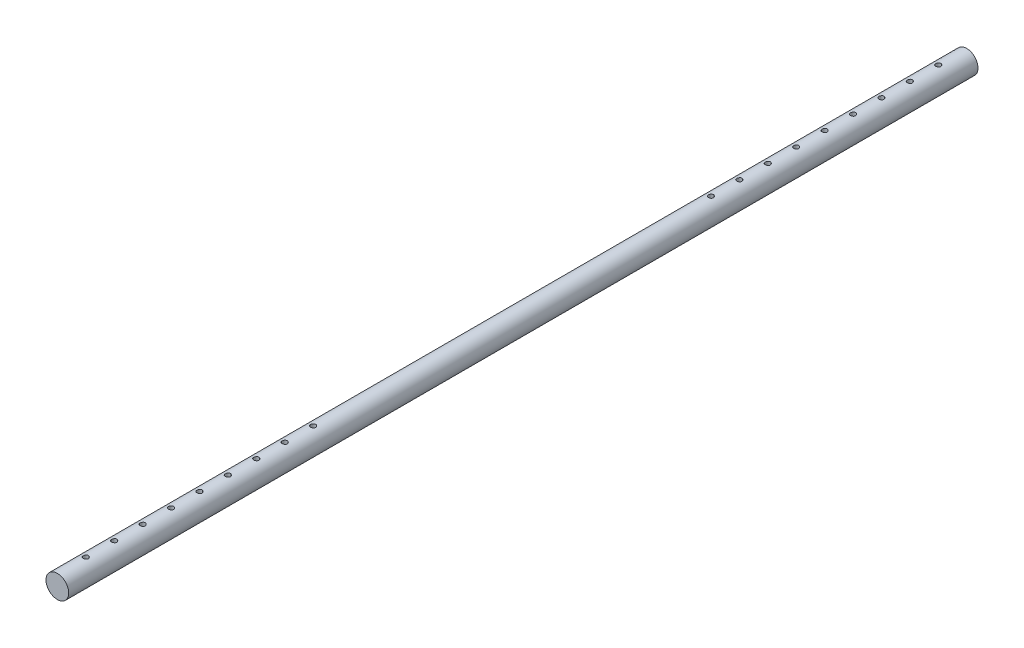
from build123d import *

# Parameters (mm, degrees)
SKETCH1_R                      = 10
BOSS_EXTRUDE1_DEPTH            = 800
CUT_EXTRUDE1_REACH             = 12
SKETCH2_R                      = 2.25
CUT_EXTRUDE1_DIRECTION_2_REACH = 12


with BuildPart() as part:
    # Sketch1 → Boss-Extrude1 (new body)
    with BuildSketch(Plane.XY):
        Circle(SKETCH1_R)
    extrude(amount=BOSS_EXTRUDE1_DEPTH)

    # Sketch2 → Cut-Extrude1 (cut, up to next)
    with BuildSketch(Plane(origin=(0, 0, 0), x_dir=(1, 0, 0), z_dir=(0, 1, 0)), mode=Mode.PRIVATE) as cut_extrude1_sk1:
        with Locations((0, -25)):
            Circle(SKETCH2_R)
    cut_extrude1_tool1 = extrude(cut_extrude1_sk1.sketch, amount=-CUT_EXTRUDE1_REACH, mode=Mode.PRIVATE) & part.part
    add(cut_extrude1_tool1.solids().sort_by_distance((0, 0, 25))[0], mode=Mode.SUBTRACT)
    # Sketch2 → Cut-Extrude1 (cut, up to next)
    with BuildSketch(Plane(origin=(0, 0, 0), x_dir=(1, 0, 0), z_dir=(0, 1, 0)), mode=Mode.PRIVATE) as cut_extrude1_sk2:
        with Locations((0, -775)):
            Circle(SKETCH2_R)
    cut_extrude1_tool2 = extrude(cut_extrude1_sk2.sketch, amount=-CUT_EXTRUDE1_REACH, mode=Mode.PRIVATE) & part.part
    add(cut_extrude1_tool2.solids().sort_by_distance((0, 0, 775))[0], mode=Mode.SUBTRACT)
    # Sketch2 → Cut-Extrude1 (cut, up to next)
    with BuildSketch(Plane(origin=(0, 0, 0), x_dir=(1, 0, 0), z_dir=(0, 1, 0)), mode=Mode.PRIVATE) as cut_extrude1_sk3:
        with Locations((0, -750)):
            Circle(SKETCH2_R)
    cut_extrude1_tool3 = extrude(cut_extrude1_sk3.sketch, amount=-CUT_EXTRUDE1_REACH, mode=Mode.PRIVATE) & part.part
    add(cut_extrude1_tool3.solids().sort_by_distance((0, 0, 750))[0], mode=Mode.SUBTRACT)
    # Sketch2 → Cut-Extrude1 (cut, up to next)
    with BuildSketch(Plane(origin=(0, 0, 0), x_dir=(1, 0, 0), z_dir=(0, 1, 0)), mode=Mode.PRIVATE) as cut_extrude1_sk4:
        with Locations((0, -725)):
            Circle(SKETCH2_R)
    cut_extrude1_tool4 = extrude(cut_extrude1_sk4.sketch, amount=-CUT_EXTRUDE1_REACH, mode=Mode.PRIVATE) & part.part
    add(cut_extrude1_tool4.solids().sort_by_distance((0, 0, 725))[0], mode=Mode.SUBTRACT)
    # Sketch2 → Cut-Extrude1 (cut, up to next)
    with BuildSketch(Plane(origin=(0, 0, 0), x_dir=(1, 0, 0), z_dir=(0, 1, 0)), mode=Mode.PRIVATE) as cut_extrude1_sk5:
        with Locations((0, -50)):
            Circle(SKETCH2_R)
    cut_extrude1_tool5 = extrude(cut_extrude1_sk5.sketch, amount=-CUT_EXTRUDE1_REACH, mode=Mode.PRIVATE) & part.part
    add(cut_extrude1_tool5.solids().sort_by_distance((0, 0, 50))[0], mode=Mode.SUBTRACT)
    # Sketch2 → Cut-Extrude1 (cut, up to next)
    with BuildSketch(Plane(origin=(0, 0, 0), x_dir=(1, 0, 0), z_dir=(0, 1, 0)), mode=Mode.PRIVATE) as cut_extrude1_sk6:
        with Locations((0, -75)):
            Circle(SKETCH2_R)
    cut_extrude1_tool6 = extrude(cut_extrude1_sk6.sketch, amount=-CUT_EXTRUDE1_REACH, mode=Mode.PRIVATE) & part.part
    add(cut_extrude1_tool6.solids().sort_by_distance((0, 0, 75))[0], mode=Mode.SUBTRACT)
    # Sketch2 → Cut-Extrude1 (cut, up to next)
    with BuildSketch(Plane(origin=(0, 0, 0), x_dir=(1, 0, 0), z_dir=(0, 1, 0)), mode=Mode.PRIVATE) as cut_extrude1_sk7:
        with Locations((0, -100)):
            Circle(SKETCH2_R)
    cut_extrude1_tool7 = extrude(cut_extrude1_sk7.sketch, amount=-CUT_EXTRUDE1_REACH, mode=Mode.PRIVATE) & part.part
    add(cut_extrude1_tool7.solids().sort_by_distance((0, 0, 100))[0], mode=Mode.SUBTRACT)
    # Sketch2 → Cut-Extrude1 (cut, up to next)
    with BuildSketch(Plane(origin=(0, 0, 0), x_dir=(1, 0, 0), z_dir=(0, 1, 0)), mode=Mode.PRIVATE) as cut_extrude1_sk8:
        with Locations((0, -125)):
            Circle(SKETCH2_R)
    cut_extrude1_tool8 = extrude(cut_extrude1_sk8.sketch, amount=-CUT_EXTRUDE1_REACH, mode=Mode.PRIVATE) & part.part
    add(cut_extrude1_tool8.solids().sort_by_distance((0, 0, 125))[0], mode=Mode.SUBTRACT)
    # Sketch2 → Cut-Extrude1 (cut, up to next)
    with BuildSketch(Plane(origin=(0, 0, 0), x_dir=(1, 0, 0), z_dir=(0, 1, 0)), mode=Mode.PRIVATE) as cut_extrude1_sk9:
        with Locations((0, -150)):
            Circle(SKETCH2_R)
    cut_extrude1_tool9 = extrude(cut_extrude1_sk9.sketch, amount=-CUT_EXTRUDE1_REACH, mode=Mode.PRIVATE) & part.part
    add(cut_extrude1_tool9.solids().sort_by_distance((0, 0, 150))[0], mode=Mode.SUBTRACT)
    # Sketch2 → Cut-Extrude1 (cut, up to next)
    with BuildSketch(Plane(origin=(0, 0, 0), x_dir=(1, 0, 0), z_dir=(0, 1, 0)), mode=Mode.PRIVATE) as cut_extrude1_sk10:
        with Locations((0, -175)):
            Circle(SKETCH2_R)
    cut_extrude1_tool10 = extrude(cut_extrude1_sk10.sketch, amount=-CUT_EXTRUDE1_REACH, mode=Mode.PRIVATE) & part.part
    add(cut_extrude1_tool10.solids().sort_by_distance((0, 0, 175))[0], mode=Mode.SUBTRACT)
    # Sketch2 → Cut-Extrude1 (cut, up to next)
    with BuildSketch(Plane(origin=(0, 0, 0), x_dir=(1, 0, 0), z_dir=(0, 1, 0)), mode=Mode.PRIVATE) as cut_extrude1_sk11:
        with Locations((0, -200)):
            Circle(SKETCH2_R)
    cut_extrude1_tool11 = extrude(cut_extrude1_sk11.sketch, amount=-CUT_EXTRUDE1_REACH, mode=Mode.PRIVATE) & part.part
    add(cut_extrude1_tool11.solids().sort_by_distance((0, 0, 200))[0], mode=Mode.SUBTRACT)
    # Sketch2 → Cut-Extrude1 (cut, up to next)
    with BuildSketch(Plane(origin=(0, 0, 0), x_dir=(1, 0, 0), z_dir=(0, 1, 0)), mode=Mode.PRIVATE) as cut_extrude1_sk12:
        with Locations((0, -225)):
            Circle(SKETCH2_R)
    cut_extrude1_tool12 = extrude(cut_extrude1_sk12.sketch, amount=-CUT_EXTRUDE1_REACH, mode=Mode.PRIVATE) & part.part
    add(cut_extrude1_tool12.solids().sort_by_distance((0, 0, 225))[0], mode=Mode.SUBTRACT)
    # Sketch2 → Cut-Extrude1 (cut, up to next)
    with BuildSketch(Plane(origin=(0, 0, 0), x_dir=(1, 0, 0), z_dir=(0, 1, 0)), mode=Mode.PRIVATE) as cut_extrude1_sk13:
        with Locations((0, -700)):
            Circle(SKETCH2_R)
    cut_extrude1_tool13 = extrude(cut_extrude1_sk13.sketch, amount=-CUT_EXTRUDE1_REACH, mode=Mode.PRIVATE) & part.part
    add(cut_extrude1_tool13.solids().sort_by_distance((0, 0, 700))[0], mode=Mode.SUBTRACT)
    # Sketch2 → Cut-Extrude1 (cut, up to next)
    with BuildSketch(Plane(origin=(0, 0, 0), x_dir=(1, 0, 0), z_dir=(0, 1, 0)), mode=Mode.PRIVATE) as cut_extrude1_sk14:
        with Locations((0, -675)):
            Circle(SKETCH2_R)
    cut_extrude1_tool14 = extrude(cut_extrude1_sk14.sketch, amount=-CUT_EXTRUDE1_REACH, mode=Mode.PRIVATE) & part.part
    add(cut_extrude1_tool14.solids().sort_by_distance((0, 0, 675))[0], mode=Mode.SUBTRACT)
    # Sketch2 → Cut-Extrude1 (cut, up to next)
    with BuildSketch(Plane(origin=(0, 0, 0), x_dir=(1, 0, 0), z_dir=(0, 1, 0)), mode=Mode.PRIVATE) as cut_extrude1_sk15:
        with Locations((0, -650)):
            Circle(SKETCH2_R)
    cut_extrude1_tool15 = extrude(cut_extrude1_sk15.sketch, amount=-CUT_EXTRUDE1_REACH, mode=Mode.PRIVATE) & part.part
    add(cut_extrude1_tool15.solids().sort_by_distance((0, 0, 650))[0], mode=Mode.SUBTRACT)
    # Sketch2 → Cut-Extrude1 (cut, up to next)
    with BuildSketch(Plane(origin=(0, 0, 0), x_dir=(1, 0, 0), z_dir=(0, 1, 0)), mode=Mode.PRIVATE) as cut_extrude1_sk16:
        with Locations((0, -625)):
            Circle(SKETCH2_R)
    cut_extrude1_tool16 = extrude(cut_extrude1_sk16.sketch, amount=-CUT_EXTRUDE1_REACH, mode=Mode.PRIVATE) & part.part
    add(cut_extrude1_tool16.solids().sort_by_distance((0, 0, 625))[0], mode=Mode.SUBTRACT)
    # Sketch2 → Cut-Extrude1 (cut, up to next)
    with BuildSketch(Plane(origin=(0, 0, 0), x_dir=(1, 0, 0), z_dir=(0, 1, 0)), mode=Mode.PRIVATE) as cut_extrude1_sk17:
        with Locations((0, -600)):
            Circle(SKETCH2_R)
    cut_extrude1_tool17 = extrude(cut_extrude1_sk17.sketch, amount=-CUT_EXTRUDE1_REACH, mode=Mode.PRIVATE) & part.part
    add(cut_extrude1_tool17.solids().sort_by_distance((0, 0, 600))[0], mode=Mode.SUBTRACT)
    # Sketch2 → Cut-Extrude1 (cut, up to next)
    with BuildSketch(Plane(origin=(0, 0, 0), x_dir=(1, 0, 0), z_dir=(0, 1, 0)), mode=Mode.PRIVATE) as cut_extrude1_sk18:
        with Locations((0, -575)):
            Circle(SKETCH2_R)
    cut_extrude1_tool18 = extrude(cut_extrude1_sk18.sketch, amount=-CUT_EXTRUDE1_REACH, mode=Mode.PRIVATE) & part.part
    add(cut_extrude1_tool18.solids().sort_by_distance((0, 0, 575))[0], mode=Mode.SUBTRACT)

    # Sketch2 → Cut-Extrude1 direction 2 (cut, up to next)
    with BuildSketch(Plane(origin=(0, 0, 0), x_dir=(1, 0, 0), z_dir=(0, 1, 0)), mode=Mode.PRIVATE) as cut_extrude1_direction_2_sk1:
        with Locations((0, -25)):
            Circle(SKETCH2_R)
    cut_extrude1_direction_2_tool1 = extrude(cut_extrude1_direction_2_sk1.sketch, amount=CUT_EXTRUDE1_DIRECTION_2_REACH, mode=Mode.PRIVATE) & part.part
    add(cut_extrude1_direction_2_tool1.solids().sort_by_distance((0, 0, 25))[0], mode=Mode.SUBTRACT)
    # Sketch2 → Cut-Extrude1 direction 2 (cut, up to next)
    with BuildSketch(Plane(origin=(0, 0, 0), x_dir=(1, 0, 0), z_dir=(0, 1, 0)), mode=Mode.PRIVATE) as cut_extrude1_direction_2_sk2:
        with Locations((0, -775)):
            Circle(SKETCH2_R)
    cut_extrude1_direction_2_tool2 = extrude(cut_extrude1_direction_2_sk2.sketch, amount=CUT_EXTRUDE1_DIRECTION_2_REACH, mode=Mode.PRIVATE) & part.part
    add(cut_extrude1_direction_2_tool2.solids().sort_by_distance((0, 0, 775))[0], mode=Mode.SUBTRACT)
    # Sketch2 → Cut-Extrude1 direction 2 (cut, up to next)
    with BuildSketch(Plane(origin=(0, 0, 0), x_dir=(1, 0, 0), z_dir=(0, 1, 0)), mode=Mode.PRIVATE) as cut_extrude1_direction_2_sk3:
        with Locations((0, -750)):
            Circle(SKETCH2_R)
    cut_extrude1_direction_2_tool3 = extrude(cut_extrude1_direction_2_sk3.sketch, amount=CUT_EXTRUDE1_DIRECTION_2_REACH, mode=Mode.PRIVATE) & part.part
    add(cut_extrude1_direction_2_tool3.solids().sort_by_distance((0, 0, 750))[0], mode=Mode.SUBTRACT)
    # Sketch2 → Cut-Extrude1 direction 2 (cut, up to next)
    with BuildSketch(Plane(origin=(0, 0, 0), x_dir=(1, 0, 0), z_dir=(0, 1, 0)), mode=Mode.PRIVATE) as cut_extrude1_direction_2_sk4:
        with Locations((0, -725)):
            Circle(SKETCH2_R)
    cut_extrude1_direction_2_tool4 = extrude(cut_extrude1_direction_2_sk4.sketch, amount=CUT_EXTRUDE1_DIRECTION_2_REACH, mode=Mode.PRIVATE) & part.part
    add(cut_extrude1_direction_2_tool4.solids().sort_by_distance((0, 0, 725))[0], mode=Mode.SUBTRACT)
    # Sketch2 → Cut-Extrude1 direction 2 (cut, up to next)
    with BuildSketch(Plane(origin=(0, 0, 0), x_dir=(1, 0, 0), z_dir=(0, 1, 0)), mode=Mode.PRIVATE) as cut_extrude1_direction_2_sk5:
        with Locations((0, -50)):
            Circle(SKETCH2_R)
    cut_extrude1_direction_2_tool5 = extrude(cut_extrude1_direction_2_sk5.sketch, amount=CUT_EXTRUDE1_DIRECTION_2_REACH, mode=Mode.PRIVATE) & part.part
    add(cut_extrude1_direction_2_tool5.solids().sort_by_distance((0, 0, 50))[0], mode=Mode.SUBTRACT)
    # Sketch2 → Cut-Extrude1 direction 2 (cut, up to next)
    with BuildSketch(Plane(origin=(0, 0, 0), x_dir=(1, 0, 0), z_dir=(0, 1, 0)), mode=Mode.PRIVATE) as cut_extrude1_direction_2_sk6:
        with Locations((0, -75)):
            Circle(SKETCH2_R)
    cut_extrude1_direction_2_tool6 = extrude(cut_extrude1_direction_2_sk6.sketch, amount=CUT_EXTRUDE1_DIRECTION_2_REACH, mode=Mode.PRIVATE) & part.part
    add(cut_extrude1_direction_2_tool6.solids().sort_by_distance((0, 0, 75))[0], mode=Mode.SUBTRACT)
    # Sketch2 → Cut-Extrude1 direction 2 (cut, up to next)
    with BuildSketch(Plane(origin=(0, 0, 0), x_dir=(1, 0, 0), z_dir=(0, 1, 0)), mode=Mode.PRIVATE) as cut_extrude1_direction_2_sk7:
        with Locations((0, -100)):
            Circle(SKETCH2_R)
    cut_extrude1_direction_2_tool7 = extrude(cut_extrude1_direction_2_sk7.sketch, amount=CUT_EXTRUDE1_DIRECTION_2_REACH, mode=Mode.PRIVATE) & part.part
    add(cut_extrude1_direction_2_tool7.solids().sort_by_distance((0, 0, 100))[0], mode=Mode.SUBTRACT)
    # Sketch2 → Cut-Extrude1 direction 2 (cut, up to next)
    with BuildSketch(Plane(origin=(0, 0, 0), x_dir=(1, 0, 0), z_dir=(0, 1, 0)), mode=Mode.PRIVATE) as cut_extrude1_direction_2_sk8:
        with Locations((0, -125)):
            Circle(SKETCH2_R)
    cut_extrude1_direction_2_tool8 = extrude(cut_extrude1_direction_2_sk8.sketch, amount=CUT_EXTRUDE1_DIRECTION_2_REACH, mode=Mode.PRIVATE) & part.part
    add(cut_extrude1_direction_2_tool8.solids().sort_by_distance((0, 0, 125))[0], mode=Mode.SUBTRACT)
    # Sketch2 → Cut-Extrude1 direction 2 (cut, up to next)
    with BuildSketch(Plane(origin=(0, 0, 0), x_dir=(1, 0, 0), z_dir=(0, 1, 0)), mode=Mode.PRIVATE) as cut_extrude1_direction_2_sk9:
        with Locations((0, -150)):
            Circle(SKETCH2_R)
    cut_extrude1_direction_2_tool9 = extrude(cut_extrude1_direction_2_sk9.sketch, amount=CUT_EXTRUDE1_DIRECTION_2_REACH, mode=Mode.PRIVATE) & part.part
    add(cut_extrude1_direction_2_tool9.solids().sort_by_distance((0, 0, 150))[0], mode=Mode.SUBTRACT)
    # Sketch2 → Cut-Extrude1 direction 2 (cut, up to next)
    with BuildSketch(Plane(origin=(0, 0, 0), x_dir=(1, 0, 0), z_dir=(0, 1, 0)), mode=Mode.PRIVATE) as cut_extrude1_direction_2_sk10:
        with Locations((0, -175)):
            Circle(SKETCH2_R)
    cut_extrude1_direction_2_tool10 = extrude(cut_extrude1_direction_2_sk10.sketch, amount=CUT_EXTRUDE1_DIRECTION_2_REACH, mode=Mode.PRIVATE) & part.part
    add(cut_extrude1_direction_2_tool10.solids().sort_by_distance((0, 0, 175))[0], mode=Mode.SUBTRACT)
    # Sketch2 → Cut-Extrude1 direction 2 (cut, up to next)
    with BuildSketch(Plane(origin=(0, 0, 0), x_dir=(1, 0, 0), z_dir=(0, 1, 0)), mode=Mode.PRIVATE) as cut_extrude1_direction_2_sk11:
        with Locations((0, -200)):
            Circle(SKETCH2_R)
    cut_extrude1_direction_2_tool11 = extrude(cut_extrude1_direction_2_sk11.sketch, amount=CUT_EXTRUDE1_DIRECTION_2_REACH, mode=Mode.PRIVATE) & part.part
    add(cut_extrude1_direction_2_tool11.solids().sort_by_distance((0, 0, 200))[0], mode=Mode.SUBTRACT)
    # Sketch2 → Cut-Extrude1 direction 2 (cut, up to next)
    with BuildSketch(Plane(origin=(0, 0, 0), x_dir=(1, 0, 0), z_dir=(0, 1, 0)), mode=Mode.PRIVATE) as cut_extrude1_direction_2_sk12:
        with Locations((0, -225)):
            Circle(SKETCH2_R)
    cut_extrude1_direction_2_tool12 = extrude(cut_extrude1_direction_2_sk12.sketch, amount=CUT_EXTRUDE1_DIRECTION_2_REACH, mode=Mode.PRIVATE) & part.part
    add(cut_extrude1_direction_2_tool12.solids().sort_by_distance((0, 0, 225))[0], mode=Mode.SUBTRACT)
    # Sketch2 → Cut-Extrude1 direction 2 (cut, up to next)
    with BuildSketch(Plane(origin=(0, 0, 0), x_dir=(1, 0, 0), z_dir=(0, 1, 0)), mode=Mode.PRIVATE) as cut_extrude1_direction_2_sk13:
        with Locations((0, -700)):
            Circle(SKETCH2_R)
    cut_extrude1_direction_2_tool13 = extrude(cut_extrude1_direction_2_sk13.sketch, amount=CUT_EXTRUDE1_DIRECTION_2_REACH, mode=Mode.PRIVATE) & part.part
    add(cut_extrude1_direction_2_tool13.solids().sort_by_distance((0, 0, 700))[0], mode=Mode.SUBTRACT)
    # Sketch2 → Cut-Extrude1 direction 2 (cut, up to next)
    with BuildSketch(Plane(origin=(0, 0, 0), x_dir=(1, 0, 0), z_dir=(0, 1, 0)), mode=Mode.PRIVATE) as cut_extrude1_direction_2_sk14:
        with Locations((0, -675)):
            Circle(SKETCH2_R)
    cut_extrude1_direction_2_tool14 = extrude(cut_extrude1_direction_2_sk14.sketch, amount=CUT_EXTRUDE1_DIRECTION_2_REACH, mode=Mode.PRIVATE) & part.part
    add(cut_extrude1_direction_2_tool14.solids().sort_by_distance((0, 0, 675))[0], mode=Mode.SUBTRACT)
    # Sketch2 → Cut-Extrude1 direction 2 (cut, up to next)
    with BuildSketch(Plane(origin=(0, 0, 0), x_dir=(1, 0, 0), z_dir=(0, 1, 0)), mode=Mode.PRIVATE) as cut_extrude1_direction_2_sk15:
        with Locations((0, -650)):
            Circle(SKETCH2_R)
    cut_extrude1_direction_2_tool15 = extrude(cut_extrude1_direction_2_sk15.sketch, amount=CUT_EXTRUDE1_DIRECTION_2_REACH, mode=Mode.PRIVATE) & part.part
    add(cut_extrude1_direction_2_tool15.solids().sort_by_distance((0, 0, 650))[0], mode=Mode.SUBTRACT)
    # Sketch2 → Cut-Extrude1 direction 2 (cut, up to next)
    with BuildSketch(Plane(origin=(0, 0, 0), x_dir=(1, 0, 0), z_dir=(0, 1, 0)), mode=Mode.PRIVATE) as cut_extrude1_direction_2_sk16:
        with Locations((0, -625)):
            Circle(SKETCH2_R)
    cut_extrude1_direction_2_tool16 = extrude(cut_extrude1_direction_2_sk16.sketch, amount=CUT_EXTRUDE1_DIRECTION_2_REACH, mode=Mode.PRIVATE) & part.part
    add(cut_extrude1_direction_2_tool16.solids().sort_by_distance((0, 0, 625))[0], mode=Mode.SUBTRACT)
    # Sketch2 → Cut-Extrude1 direction 2 (cut, up to next)
    with BuildSketch(Plane(origin=(0, 0, 0), x_dir=(1, 0, 0), z_dir=(0, 1, 0)), mode=Mode.PRIVATE) as cut_extrude1_direction_2_sk17:
        with Locations((0, -600)):
            Circle(SKETCH2_R)
    cut_extrude1_direction_2_tool17 = extrude(cut_extrude1_direction_2_sk17.sketch, amount=CUT_EXTRUDE1_DIRECTION_2_REACH, mode=Mode.PRIVATE) & part.part
    add(cut_extrude1_direction_2_tool17.solids().sort_by_distance((0, 0, 600))[0], mode=Mode.SUBTRACT)
    # Sketch2 → Cut-Extrude1 direction 2 (cut, up to next)
    with BuildSketch(Plane(origin=(0, 0, 0), x_dir=(1, 0, 0), z_dir=(0, 1, 0)), mode=Mode.PRIVATE) as cut_extrude1_direction_2_sk18:
        with Locations((0, -575)):
            Circle(SKETCH2_R)
    cut_extrude1_direction_2_tool18 = extrude(cut_extrude1_direction_2_sk18.sketch, amount=CUT_EXTRUDE1_DIRECTION_2_REACH, mode=Mode.PRIVATE) & part.part
    add(cut_extrude1_direction_2_tool18.solids().sort_by_distance((0, 0, 575))[0], mode=Mode.SUBTRACT)


solid = part.part
